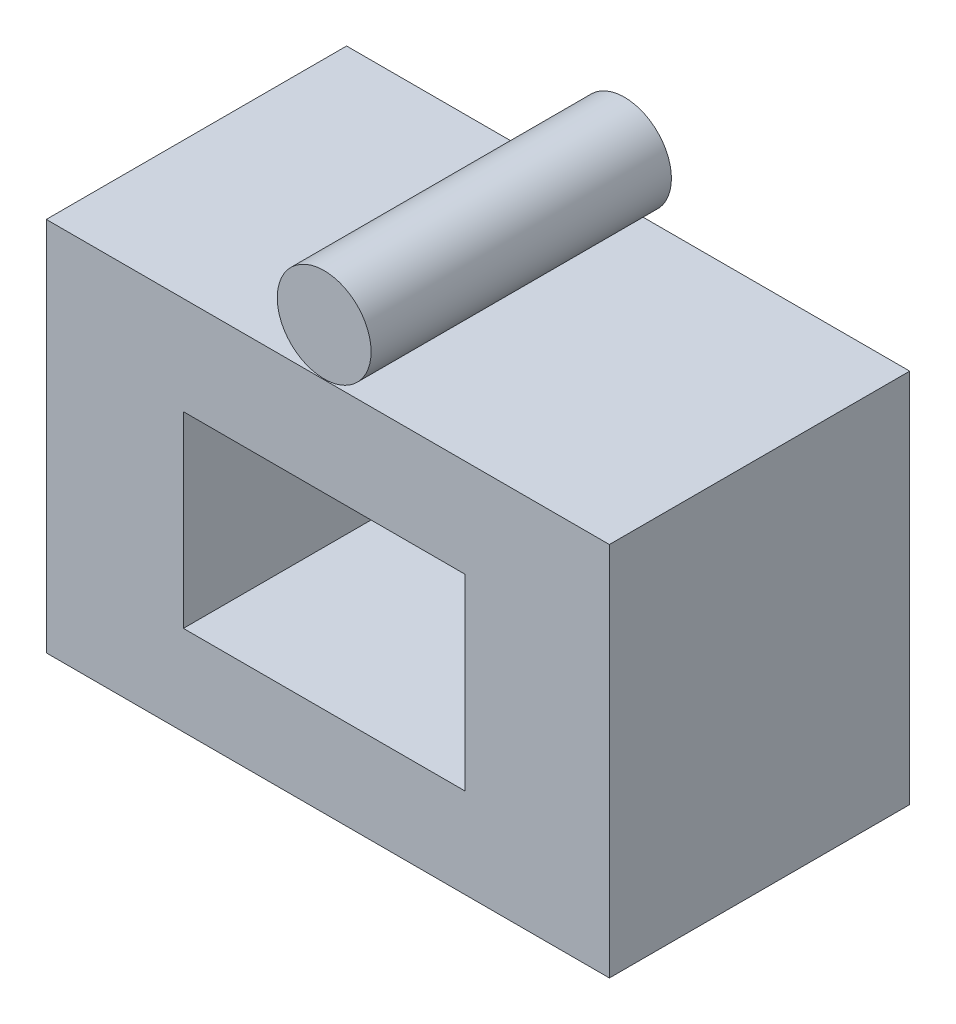
from build123d import *

# Parameters (mm, degrees)
ESQUISSE1_W        = 150
ESQUISSE1_H        = 100
ESQUISSE1_W_2      = 75
ESQUISSE1_H_2      = 50
BOSS_EXTRU_1_DEPTH = 80
ESQUISSE3_R        = 12.5
BOSS_EXTRU_2_DEPTH = 80


with BuildPart() as part:
    # Esquisse1 → Boss.-Extru.1 (new body)
    with BuildSketch(Plane.XY):
        with Locations((12.608695652, -9.02173913)):
            Rectangle(ESQUISSE1_W, ESQUISSE1_H)
        with Locations((11.630434783, -10.108695652)):
            Rectangle(ESQUISSE1_W_2, ESQUISSE1_H_2, mode=Mode.SUBTRACT)
    extrude(amount=BOSS_EXTRU_1_DEPTH)


with BuildPart() as body_2:
    # Esquisse3 → Boss.-Extru.2 (new body)
    with BuildSketch(Plane.XY.offset(80)):
        with Locations((11.630434783, 53.681823265)):
            Circle(ESQUISSE3_R)
    extrude(amount=-BOSS_EXTRU_2_DEPTH)


solid = Compound([part.part, body_2.part])
